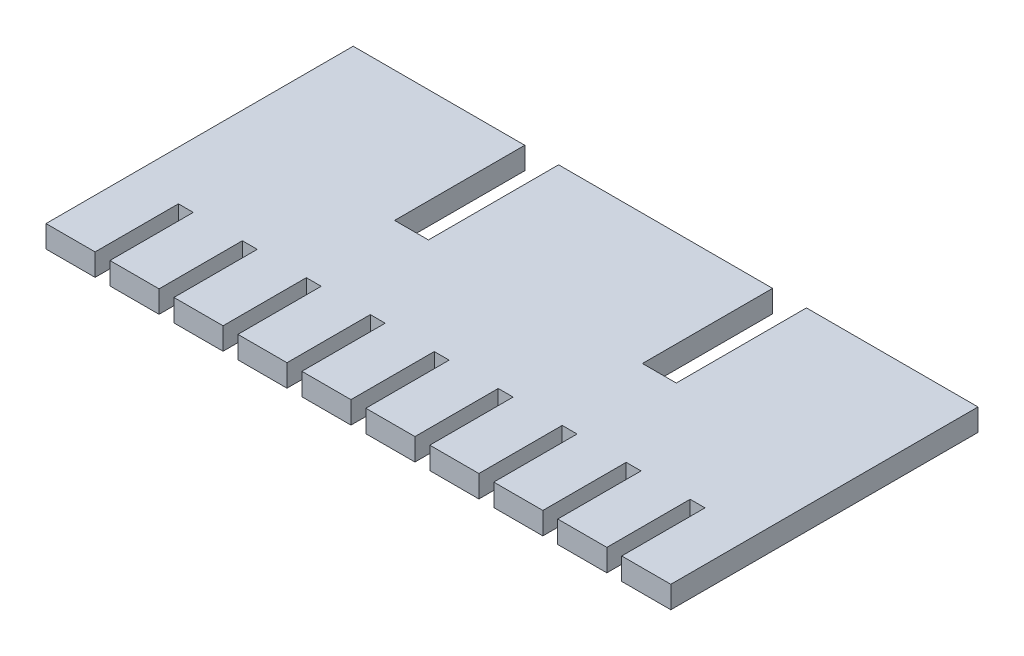
from build123d import *

# Parameters (mm, degrees)
BOSS_EXTRUDE2_DEPTH = 2.121


with BuildPart() as part:
    # Sketch1 → Boss-Extrude2 (new body)
    with BuildSketch(Plane(origin=(0, 0, 0), x_dir=(1, 0, 0), z_dir=(0, 1, 0))):
        Polygon((0, 0), (0, -29.5), (4.7139, -29.5), (4.7139, -21.5), (6.1429, -21.5), (6.1429, -29.5), (10.8568, -29.5), (10.8568, -21.5), (12.2858, -21.5), (12.2858, -29.5), (16.9997, -29.5), (16.9997, -21.5), (18.4287, -21.5), (18.4287, -29.5), (23.1426, -29.5), (23.1426, -21.5), (24.5716, -21.5), (24.5716, -29.5), (29.2855, -29.5), (29.2855, -21.5), (30.7145, -21.5), (30.7145, -29.5), (35.4284, -29.5), (35.4284, -21.5), (36.8574, -21.5), (36.8574, -29.5), (41.5713, -29.5), (41.5713, -21.5), (43.0003, -21.5), (43.0003, -29.5), (47.7142, -29.5), (47.7142, -21.5), (49.1432, -21.5), (49.1432, -29.5), (53.8571, -29.5), (53.8571, -21.5), (55.2861, -21.5), (55.2861, -29.5), (60, -29.5), (60, 0), (43.525, 0), (43.525, -12.5), (40.275, -12.5), (40.275, 0), (19.725, 0), (19.725, -12.5), (16.475, -12.5), (16.475, 0), align=None)
    extrude(amount=BOSS_EXTRUDE2_DEPTH)


solid = part.part
